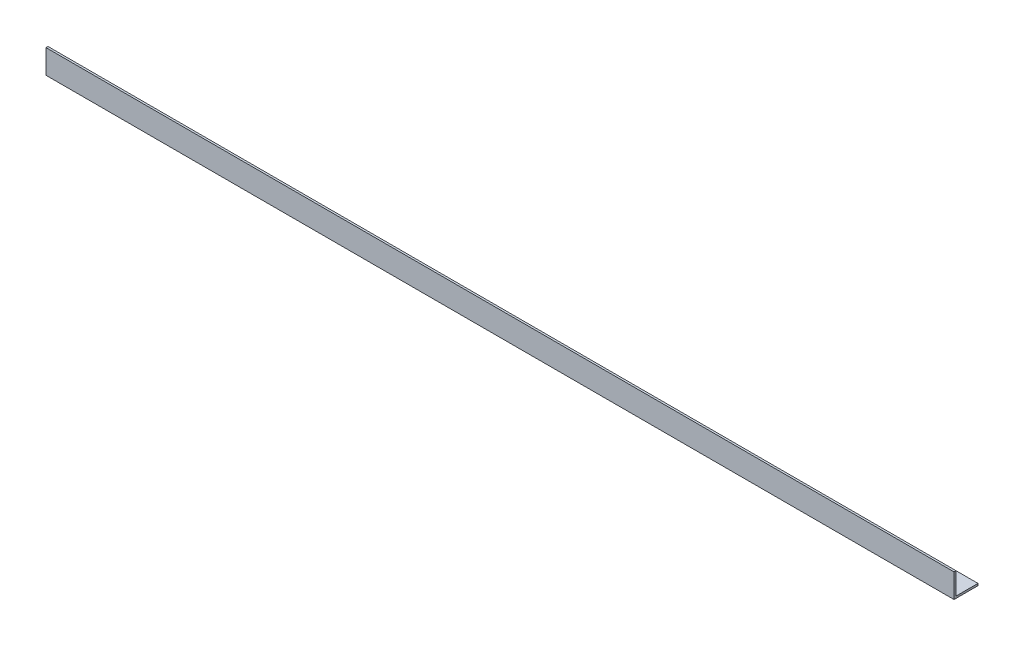
from build123d import *

# Parameters (mm, degrees)
EXTRUDE_THIN1_DEPTH = 720.852


with BuildPart() as part:
    # Sketch1 → Extrude-Thin1 (new body)
    with BuildSketch(Plane(origin=(0, 0, 0), x_dir=(0, 0, -1), z_dir=(1, 0, 0))):
        Polygon((0, 19.05), (0, 0), (19.05, 0), (19.05, 1.5875), (1.5875, 1.5875), (1.5875, 19.05), align=None)
    extrude(amount=EXTRUDE_THIN1_DEPTH)


solid = part.part
